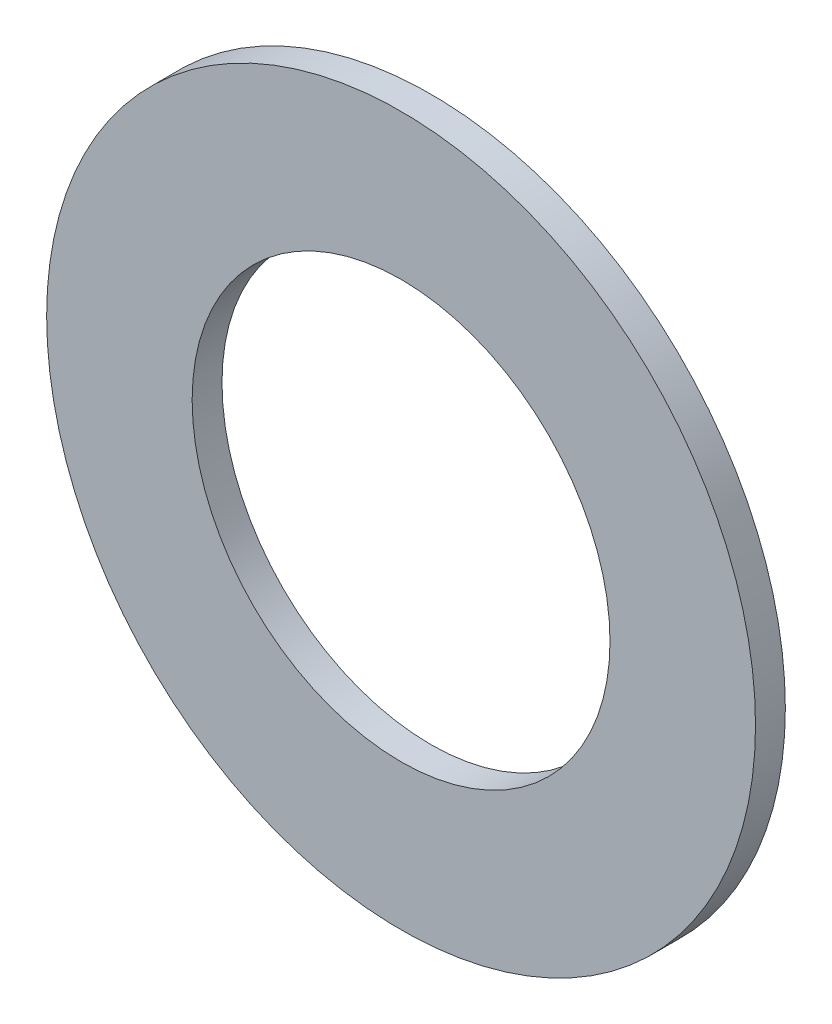
from build123d import *

# Parameters (mm, degrees)
SKETCH1_R          = 6.0325
SKETCH1_R_2        = 3.556
BASE_EXTRUDE_DEPTH = 0.508


with BuildPart() as part:
    # Sketch1 → Base-Extrude (new body)
    with BuildSketch(Plane.XY):
        Circle(SKETCH1_R)
        Circle(SKETCH1_R_2, mode=Mode.SUBTRACT)
    extrude(amount=BASE_EXTRUDE_DEPTH)


solid = part.part
